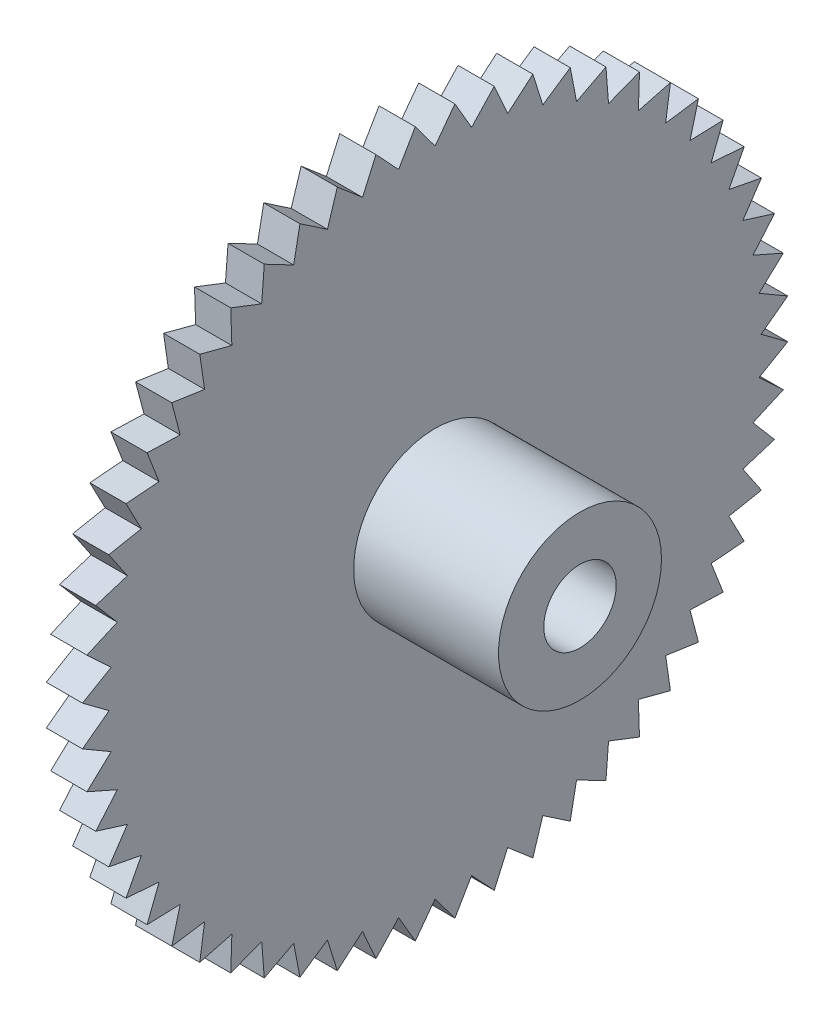
from build123d import *

# Parameters (mm, degrees)
SKETCH1_R           = 19.5
BOSS_EXTRUDE1_DEPTH = 2
SKETCH2_R           = 4.5
BOSS_EXTRUDE2_DEPTH = 8
SKETCH3_R           = 4.5
BOSS_EXTRUDE3_DEPTH = 1
SKETCH4_R           = 2
CUT_EXTRUDE1_DEPTH  = 11
CUT_EXTRUDE5_DEPTH  = 2
CIRPATTERN1_COUNT   = 56


with BuildPart() as part:
    # Sketch1 → Boss-Extrude1 (new body)
    with BuildSketch(Plane(origin=(0, 0, 0), x_dir=(0, 0, -1), z_dir=(1, 0, 0))):
        Circle(SKETCH1_R)
    extrude(amount=BOSS_EXTRUDE1_DEPTH)

    # Sketch2 → Boss-Extrude2 (add)
    with BuildSketch(Plane(origin=(2, 0, 0), x_dir=(0, 0, -1), z_dir=(1, 0, 0))):
        Circle(SKETCH2_R)
    extrude(amount=BOSS_EXTRUDE2_DEPTH)

    # Sketch3 → Boss-Extrude3 (add)
    with BuildSketch(Plane.ZY):
        Circle(SKETCH3_R)
    extrude(amount=BOSS_EXTRUDE3_DEPTH)

    # Sketch4 → Cut-Extrude1 (cut)
    with BuildSketch(Plane(origin=(10, 0, 0), x_dir=(0, 0, -1), z_dir=(1, 0, 0))):
        Circle(SKETCH4_R)
    extrude(amount=-CUT_EXTRUDE1_DEPTH, mode=Mode.SUBTRACT)

    # Sketch5 → Cut-Extrude5 (cut)
    with BuildSketch(Plane.ZY):
        with BuildLine():
            Line((-1.093373721, 19.469322893), (0, 18))
            Line((0, 18), (1.09337372, 19.469322893))
            ThreePointArc((1.09337372, 19.469322893), (-1e-09, 19.5), (-1.093373721, 19.469322893))
        make_face()
    cut_extrude5 = extrude(amount=-CUT_EXTRUDE5_DEPTH, mode=Mode.SUBTRACT)

    # CirPattern1: Cut-Extrude5 ×56 about axis
    cirpattern1_axis = Axis((0, 0, 0), (1, 0, 0))
    for i in range(1, CIRPATTERN1_COUNT):
        add(cut_extrude5.rotate(cirpattern1_axis, i * 360 / CIRPATTERN1_COUNT), mode=Mode.SUBTRACT)


solid = part.part
